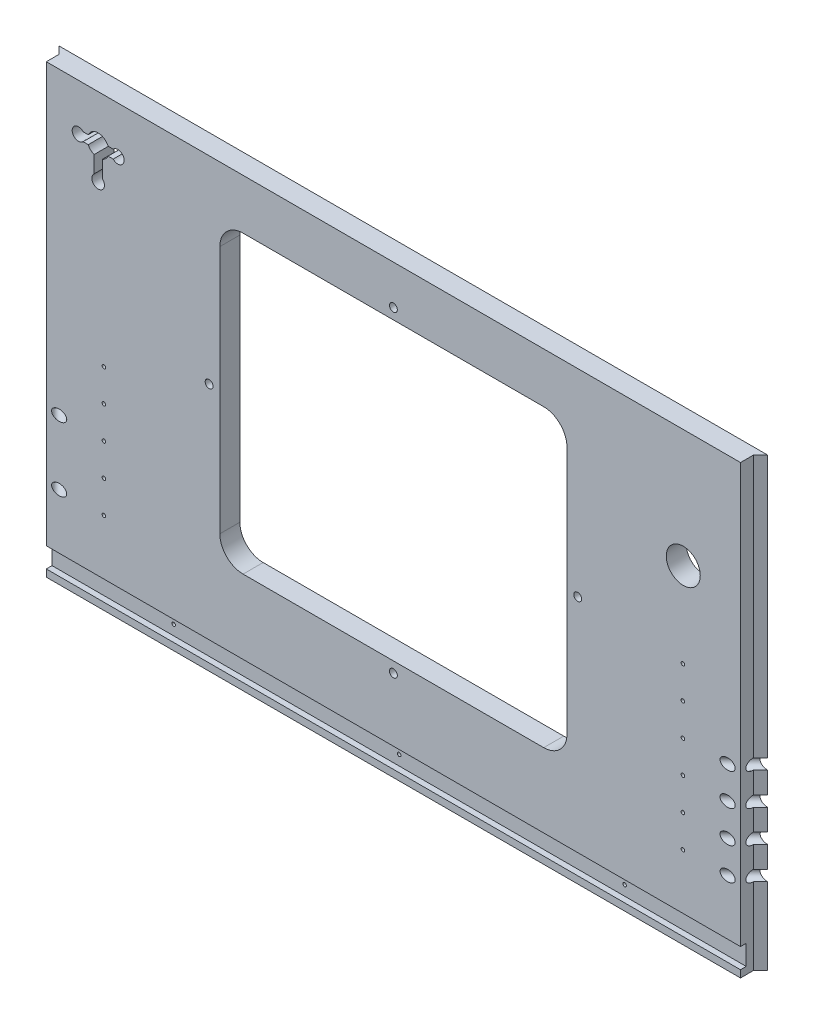
from build123d import *

# Parameters (mm, degrees)
CABFRONTOUTLINE_W               = 628.65
CABFRONTOUTLINE_H               = 396.08125
CABFRONT_THICKNESS_DEPTH        = 17.78
CABFRONT_COINDOORCUTS_R         = 1.5875
CABFRONT_COINDOORCUTS_R_2       = 15.08125
CABFRONT_COINDOORCUTS_R_3       = 3.4925
CABFRONT_COINDOORCUTS_W         = 308.0004
CABFRONT_COINDOORCUTS_H         = 261.9629
CUT_EXTRUDE1_DEPTH              = 17.78
CABFRONTBOTTOMLEDGE_DEPTH_DEPTH = 5.08
CUT_EXTRUDE4_DEPTH              = 396.08125
FILLET1_R                       = 20.6502
SKETCH2_R                       = 4.7625
CUT_EXTRUDE5_DEPTH              = 76.2
SKETCH3_R                       = 4.7625
CUT_EXTRUDE6_DEPTH              = 76.2
SKETCH4_R                       = 4.7625
CUT_EXTRUDE7_DEPTH              = 76.2


with BuildPart() as part:
    # CabFrontOutline → CabFront_Thickness (new body)
    with BuildSketch(Plane.XY):
        with Locations((12009.966666666, -5854.303125)):
            Rectangle(CABFRONTOUTLINE_W, CABFRONTOUTLINE_H)
    extrude(amount=-CABFRONT_THICKNESS_DEPTH)

    # CabFront_CoinDoorCuts → Cut-Extrude1 (cut)
    with BuildSketch(Plane.XY):
        with Locations((11753.109166666, -5893.59375)):
            Circle(CABFRONT_COINDOORCUTS_R)
        with Locations((11753.109166666, -5950.74375)):
            Circle(CABFRONT_COINDOORCUTS_R)
        with Locations((12266.824166666, -5893.59375)):
            Circle(CABFRONT_COINDOORCUTS_R)
        with Locations((12266.824166666, -5950.74375)):
            Circle(CABFRONT_COINDOORCUTS_R)
        with Locations((12266.824166666, -5836.44375)):
            Circle(CABFRONT_COINDOORCUTS_R)
        with Locations((12267.141666666, -5761.0375)):
            Circle(CABFRONT_COINDOORCUTS_R_2)
        with Locations((12173.479166666, -5831.68125)):
            Circle(CABFRONT_COINDOORCUTS_R_3)
        with Locations((12266.824166666, -5865.01875)):
            Circle(CABFRONT_COINDOORCUTS_R)
        with Locations((12266.824166666, -5922.16875)):
            Circle(CABFRONT_COINDOORCUTS_R)
        with Locations((12266.824166666, -5979.31875)):
            Circle(CABFRONT_COINDOORCUTS_R)
        with Locations((12209.991666666, -6037.10375)):
            Circle(CABFRONT_COINDOORCUTS_R)
        with Locations((12009.966666666, -6037.10375)):
            Circle(CABFRONT_COINDOORCUTS_R)
        with Locations((11809.941666666, -6037.10375)):
            Circle(CABFRONT_COINDOORCUTS_R)
        with Locations((11753.109166666, -5979.31875)):
            Circle(CABFRONT_COINDOORCUTS_R)
        with Locations((11753.109166666, -5922.16875)):
            Circle(CABFRONT_COINDOORCUTS_R)
        with Locations((11753.109166666, -5865.01875)):
            Circle(CABFRONT_COINDOORCUTS_R)
        with Locations((11846.454166666, -5831.68125)):
            Circle(CABFRONT_COINDOORCUTS_R_3)
        with Locations((12009.966666666, -5972.175)):
            Circle(CABFRONT_COINDOORCUTS_R_3)
        with Locations((12009.966666666, -5691.1875)):
            Circle(CABFRONT_COINDOORCUTS_R_3)
        with Locations((12009.966666666, -5831.68125)):
            Rectangle(CABFRONT_COINDOORCUTS_W, CABFRONT_COINDOORCUTS_H)
        with BuildLine():
            Line((11734.654409808, -5693.754968556), (11739.23011943, -5693.754968556))
            ThreePointArc((11739.23011943, -5693.754968556), (11748.029166666, -5687.976468556), (11756.828213901, -5693.754968556))
            Line((11756.828213901, -5693.754968556), (11761.386355753, -5693.754968556))
            ThreePointArc((11761.386355753, -5693.754968556), (11767.531113043, -5692.357368906), (11771.079666666, -5697.564968556))
            ThreePointArc((11771.079666666, -5697.564968556), (11767.531113043, -5702.772568206), (11761.386355753, -5701.374968556))
            Line((11761.386355753, -5701.374968556), (11756.828213901, -5701.374968556))
            ThreePointArc((11756.828213901, -5701.374968556), (11754.760305425, -5704.393665595), (11751.712166666, -5706.417925308))
            Line((11751.712166666, -5706.417925308), (11751.712166666, -5721.30243896))
            ThreePointArc((11751.712166666, -5721.30243896), (11748.029166666, -5731.092968556), (11744.346166666, -5721.30243896))
            Line((11744.346166666, -5721.30243896), (11744.346166666, -5706.417925308))
            ThreePointArc((11744.346166666, -5706.417925308), (11741.298027907, -5704.393665595), (11739.23011943, -5701.374968556))
            Line((11739.23011943, -5701.374968556), (11734.654409809, -5701.374968556))
            ThreePointArc((11734.654409809, -5701.374968556), (11724.978666666, -5697.564968556), (11734.654409808, -5693.754968556))
        make_face()
    extrude(amount=-CUT_EXTRUDE1_DEPTH, mode=Mode.SUBTRACT)

    # CabFront_BottomLedge → CabFrontBottomLedge_Depth (cut)
    with BuildSketch(Plane.XY):
        Polygon((11975.041666666, -6028.21375), (11695.641666666, -6028.21375), (11695.641666666, -6045.99375), (12324.291666666, -6045.99375), (12324.291666666, -6028.21375), align=None)
    extrude(amount=-CABFRONTBOTTOMLEDGE_DEPTH_DEPTH, mode=Mode.SUBTRACT)

    # CabFront_EdgeBevel → Cut-Extrude4 (cut)
    with BuildSketch(Plane.XZ.offset(6052.34375)):
        Polygon((11701.991666666, -11.43), (11701.991666666, 0), (11695.641666666, 0), (11695.641666666, -17.78), align=None)
        Polygon((12317.941666666, -11.43), (12324.291666666, -17.78), (12324.291666666, 0), (12317.941666666, 0), align=None)
    extrude(amount=-CUT_EXTRUDE4_DEPTH, mode=Mode.SUBTRACT)

    # Fillet1
    fillet1_edges = [part.edges().sort_by_distance(p)[0] for p in [
        (11855.966466666, -5962.6627, -8.89),
        (11855.966466666, -5700.6998, -8.89),
        (12163.966866666, -5700.6998, -8.89),
        (12163.966866666, -5962.6627, -8.89),
    ]]
    fillet(fillet1_edges, radius=FILLET1_R)

    # Sketch2 → Cut-Extrude5 (cut)
    with BuildSketch(Plane(origin=(5872.794384557, 0, 5872.794384557), x_dir=(0.707106781, 0, -0.707106781), z_dir=(0.707106781, 0, 0.707106781))):
        with Locations((8282.639891397, -5922.16875)):
            Circle(SKETCH2_R)
        with Locations((8282.639891397, -5979.31875)):
            Circle(SKETCH2_R)
    extrude(amount=-CUT_EXTRUDE5_DEPTH, mode=Mode.SUBTRACT)

    # Sketch3 → Cut-Extrude6 (cut)
    with BuildSketch(Plane(origin=(6137.172282109, 0, -6137.172282109), x_dir=(0.707106781, 0, 0.707106781), z_dir=(-0.707106781, 0, 0.707106781))):
        with Locations((8702.017852251, -5922.16875)):
            Circle(SKETCH3_R)
        with Locations((8702.017852251, -5979.31875)):
            Circle(SKETCH3_R)
    extrude(amount=-CUT_EXTRUDE6_DEPTH, mode=Mode.SUBTRACT)

    # Sketch4 → Cut-Extrude7 (cut)
    with BuildSketch(Plane(origin=(6137.165932109, 0, -6137.165932109), x_dir=(0.707106781, 0, 0.707106781), z_dir=(-0.707106781, 0, 0.707106781))):
        with Locations((8702.008871995, -5950.74375)):
            Circle(SKETCH4_R)
        with Locations((8702.008871995, -5893.59375)):
            Circle(SKETCH4_R)
    extrude(amount=-CUT_EXTRUDE7_DEPTH, mode=Mode.SUBTRACT)


solid = part.part
